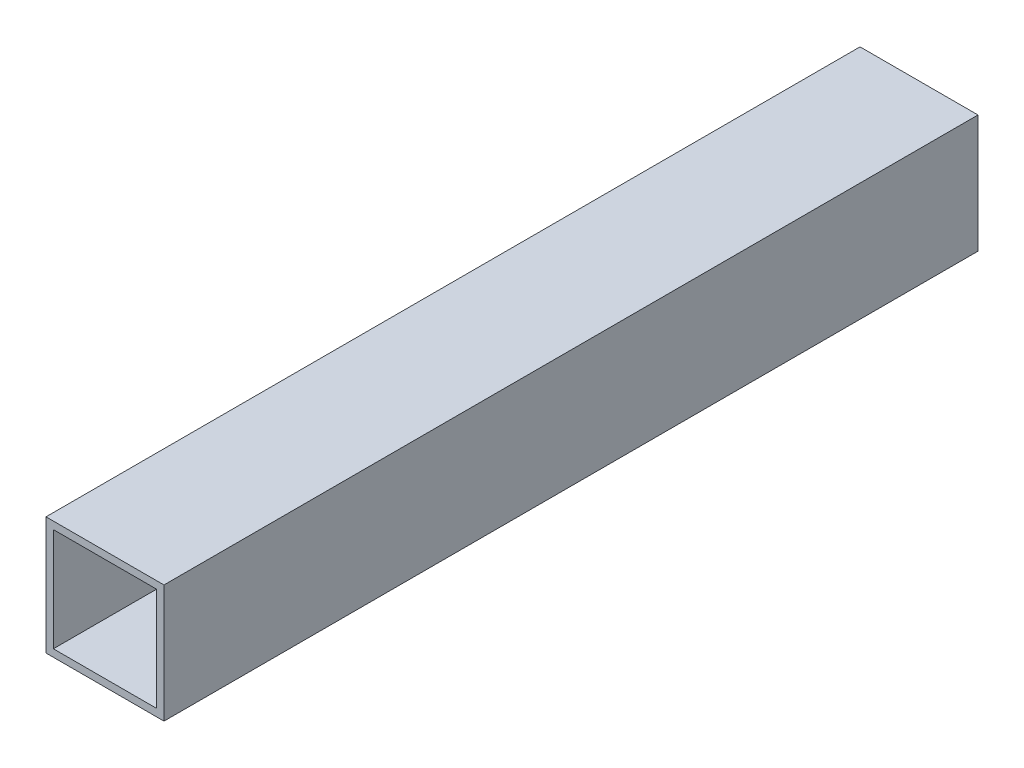
from build123d import *

# Parameters (mm, degrees)
SKETCH1_W           = 25.4
SKETCH1_H           = 25.4
BOSS_EXTRUDE1_DEPTH = 87.63
SKETCH2_W           = 22.225
SKETCH2_H           = 22.225
CUT_EXTRUDE1_DEPTH  = 176.26


with BuildPart() as part:
    # Sketch1 → Boss-Extrude1 (new body, symmetric)
    with BuildSketch(Plane.XY):
        Rectangle(SKETCH1_W, SKETCH1_H)
    extrude(amount=BOSS_EXTRUDE1_DEPTH, both=True)

    # Sketch2 → Cut-Extrude1 (cut, through all)
    with BuildSketch(Plane.XY.offset(87.63)):
        Rectangle(SKETCH2_W, SKETCH2_H)
    extrude(amount=-CUT_EXTRUDE1_DEPTH, mode=Mode.SUBTRACT)


solid = part.part
